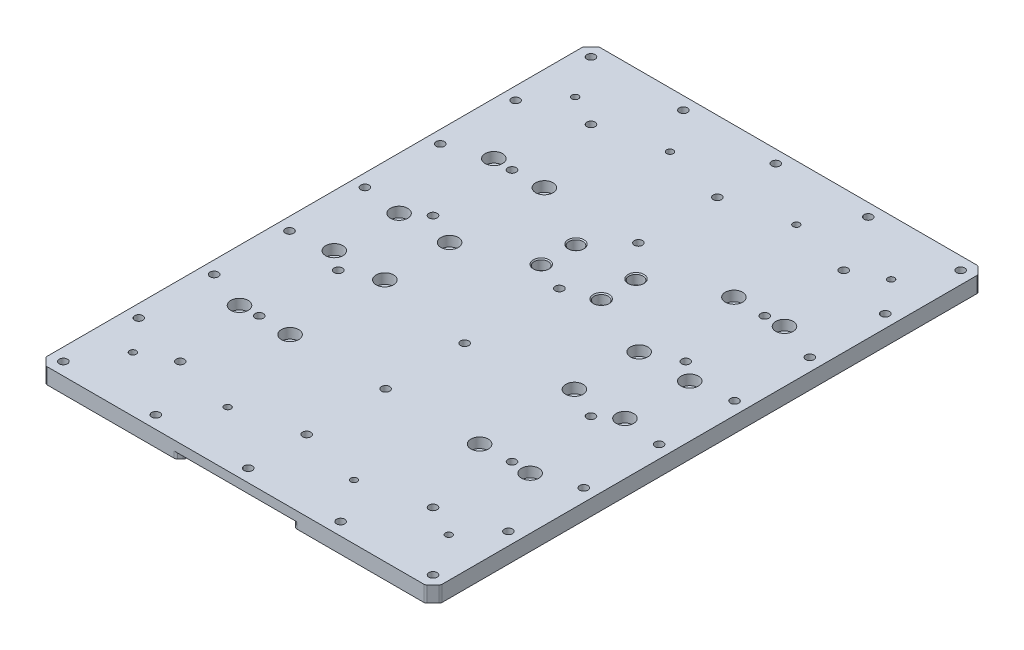
from build123d import *

# Parameters (mm, degrees)
SKETCH1_W                                           = 250
SKETCH1_H                                           = 350
BOSS_EXTRUDE1_DEPTH                                 = 10
CBORE_FOR_M5_HEX_SOCKET_HEAD_CAP_SCR_2_COUNT        = 2
CBORE_FOR_M5_HEX_SOCKET_HEAD_CAP_SCR_2_PITCH        = 22
CBORE_FOR_M5_HEX_SOCKET_HEAD_CAP_SCR_3_COUNT        = 2
CBORE_FOR_M5_HEX_SOCKET_HEAD_CAP_SCR_3_PITCH        = 43.9089968
CBORE_FOR_M5_HEX_SOCKET_HEAD_CAP_SCR_4_COUNT        = 2
CBORE_FOR_M5_HEX_SOCKET_HEAD_CAP_SCR_4_PITCH        = 38
CHAMFER1_SIZE                                       = 5
CUT_EXTRUDE1_REACH                                  = 12
SKETCH4_R                                           = 2.6
CBORE_FOR_M6_HEX_SOCKET_HEAD_CAP_SCREW1_D           = 6.2
CBORE_FOR_M6_HEX_SOCKET_HEAD_CAP_SCREW1_CBORE_D     = 11
CBORE_FOR_M6_HEX_SOCKET_HEAD_CAP_SCREW1_CBORE_DEPTH = 6.4
SKETCH7_W                                           = 70
SKETCH7_H                                           = 160
CUT_EXTRUDE2_DEPTH                                  = 4
CHAMFER2_SIZE                                       = 3
FILLET1_R                                           = 2
M5_TAPPED_HOLE1_D                                   = 4.2
M5_TAPPED_HOLE1_DEPTH                               = 14
M5_TAPPED_HOLE1_TIP                                 = 1.2618073
M6_TAPPED_HOLE1_D                                   = 5.2
M6_TAPPED_HOLE1_DEPTH                               = 17
M6_TAPPED_HOLE1_TIP                                 = 1.562237609


with BuildPart() as part:
    # Sketch1 → Boss-Extrude1 (new body)
    with BuildSketch(Plane(origin=(0, 0, 0), x_dir=(1, 0, 0), z_dir=(0, 1, 0))):
        with Locations((125, 175)):
            Rectangle(SKETCH1_W, SKETCH1_H)
    extrude(amount=BOSS_EXTRUDE1_DEPTH)

    # Sketch3 → CBORE for M5 Hex Socket Head Cap Screw1 (revolve, cut)
    with BuildSketch(Plane(origin=(106, 10, -234.5), x_dir=(0, 0, 1), z_dir=(1, 0, 0))):
        Polygon((0, 0), (0, 10), (2.75, 10), (2.75, 6.5), (4.4, 6.5), (4.4, 0.625), (5.025, 0), align=None)
    cbore_for_m5_hex_socket_head_cap_screw1 = revolve(axis=Axis((106, 16.35, -234.5), (0, -1, 0)), mode=Mode.SUBTRACT)

    # CBORE for M5 Hex Socket Head Cap Scr 2: CBORE for M5 Hex Socket Head Cap Screw1 ×2
    with Locations(*[(0, 0, i * CBORE_FOR_M5_HEX_SOCKET_HEAD_CAP_SCR_2_PITCH) for i in range(1, CBORE_FOR_M5_HEX_SOCKET_HEAD_CAP_SCR_2_COUNT)]):
        add(cbore_for_m5_hex_socket_head_cap_screw1, mode=Mode.SUBTRACT)

    # CBORE for M5 Hex Socket Head Cap Scr 3: CBORE for M5 Hex Socket Head Cap Screw1 ×2
    with Locations(*[Vector(0.865426285, 0, 0.501036271) * (i * CBORE_FOR_M5_HEX_SOCKET_HEAD_CAP_SCR_3_PITCH) for i in range(1, CBORE_FOR_M5_HEX_SOCKET_HEAD_CAP_SCR_3_COUNT)]):
        add(cbore_for_m5_hex_socket_head_cap_screw1, mode=Mode.SUBTRACT)

    # CBORE for M5 Hex Socket Head Cap Scr 4: CBORE for M5 Hex Socket Head Cap Screw1 ×2
    with Locations(*[(i * CBORE_FOR_M5_HEX_SOCKET_HEAD_CAP_SCR_4_PITCH, 0, 0) for i in range(1, CBORE_FOR_M5_HEX_SOCKET_HEAD_CAP_SCR_4_COUNT)]):
        add(cbore_for_m5_hex_socket_head_cap_screw1, mode=Mode.SUBTRACT)

    # Chamfer1
    chamfer1_edges = [part.edges().sort_by_distance(p)[0] for p in [
        (0, 5, 0),
        (0, 5, -350),
        (250, 5, -350),
        (250, 5, 0),
    ]]
    chamfer(chamfer1_edges, length=CHAMFER1_SIZE)

    # Sketch4 → Cut-Extrude1 (cut, up to next)
    with BuildSketch(Plane(origin=(0, 10, 0), x_dir=(1, 0, 0), z_dir=(0, 1, 0)), mode=Mode.PRIVATE) as cut_extrude1_sk1:
        with Locations((8, 342)):
            Circle(SKETCH4_R)
    cut_extrude1_tool1 = extrude(cut_extrude1_sk1.sketch, amount=-CUT_EXTRUDE1_REACH, mode=Mode.PRIVATE) & part.part
    add(cut_extrude1_tool1.solids().sort_by_distance((8, 10, -342))[0], mode=Mode.SUBTRACT)
    # Sketch4 → Cut-Extrude1 (cut, up to next)
    with BuildSketch(Plane(origin=(0, 10, 0), x_dir=(1, 0, 0), z_dir=(0, 1, 0)), mode=Mode.PRIVATE) as cut_extrude1_sk2:
        with Locations((66.5, 342)):
            Circle(SKETCH4_R)
    cut_extrude1_tool2 = extrude(cut_extrude1_sk2.sketch, amount=-CUT_EXTRUDE1_REACH, mode=Mode.PRIVATE) & part.part
    add(cut_extrude1_tool2.solids().sort_by_distance((66.5, 10, -342))[0], mode=Mode.SUBTRACT)
    # Sketch4 → Cut-Extrude1 (cut, up to next)
    with BuildSketch(Plane(origin=(0, 10, 0), x_dir=(1, 0, 0), z_dir=(0, 1, 0)), mode=Mode.PRIVATE) as cut_extrude1_sk3:
        with Locations((125, 342)):
            Circle(SKETCH4_R)
    cut_extrude1_tool3 = extrude(cut_extrude1_sk3.sketch, amount=-CUT_EXTRUDE1_REACH, mode=Mode.PRIVATE) & part.part
    add(cut_extrude1_tool3.solids().sort_by_distance((125, 10, -342))[0], mode=Mode.SUBTRACT)
    # Sketch4 → Cut-Extrude1 (cut, up to next)
    with BuildSketch(Plane(origin=(0, 10, 0), x_dir=(1, 0, 0), z_dir=(0, 1, 0)), mode=Mode.PRIVATE) as cut_extrude1_sk4:
        with Locations((8, 294.286)):
            Circle(SKETCH4_R)
    cut_extrude1_tool4 = extrude(cut_extrude1_sk4.sketch, amount=-CUT_EXTRUDE1_REACH, mode=Mode.PRIVATE) & part.part
    add(cut_extrude1_tool4.solids().sort_by_distance((8, 10, -294.286))[0], mode=Mode.SUBTRACT)
    # Sketch4 → Cut-Extrude1 (cut, up to next)
    with BuildSketch(Plane(origin=(0, 10, 0), x_dir=(1, 0, 0), z_dir=(0, 1, 0)), mode=Mode.PRIVATE) as cut_extrude1_sk5:
        with Locations((8, 246.572)):
            Circle(SKETCH4_R)
    cut_extrude1_tool5 = extrude(cut_extrude1_sk5.sketch, amount=-CUT_EXTRUDE1_REACH, mode=Mode.PRIVATE) & part.part
    add(cut_extrude1_tool5.solids().sort_by_distance((8, 10, -246.572))[0], mode=Mode.SUBTRACT)
    # Sketch4 → Cut-Extrude1 (cut, up to next)
    with BuildSketch(Plane(origin=(0, 10, 0), x_dir=(1, 0, 0), z_dir=(0, 1, 0)), mode=Mode.PRIVATE) as cut_extrude1_sk6:
        with Locations((8, 198.858)):
            Circle(SKETCH4_R)
    cut_extrude1_tool6 = extrude(cut_extrude1_sk6.sketch, amount=-CUT_EXTRUDE1_REACH, mode=Mode.PRIVATE) & part.part
    add(cut_extrude1_tool6.solids().sort_by_distance((8, 10, -198.858))[0], mode=Mode.SUBTRACT)
    # Sketch4 → Cut-Extrude1 (cut, up to next)
    with BuildSketch(Plane(origin=(0, 10, 0), x_dir=(1, 0, 0), z_dir=(0, 1, 0)), mode=Mode.PRIVATE) as cut_extrude1_sk7:
        with Locations((183.5, 342)):
            Circle(SKETCH4_R)
    cut_extrude1_tool7 = extrude(cut_extrude1_sk7.sketch, amount=-CUT_EXTRUDE1_REACH, mode=Mode.PRIVATE) & part.part
    add(cut_extrude1_tool7.solids().sort_by_distance((183.5, 10, -342))[0], mode=Mode.SUBTRACT)
    # Sketch4 → Cut-Extrude1 (cut, up to next)
    with BuildSketch(Plane(origin=(0, 10, 0), x_dir=(1, 0, 0), z_dir=(0, 1, 0)), mode=Mode.PRIVATE) as cut_extrude1_sk8:
        with Locations((242, 198.858)):
            Circle(SKETCH4_R)
    cut_extrude1_tool8 = extrude(cut_extrude1_sk8.sketch, amount=-CUT_EXTRUDE1_REACH, mode=Mode.PRIVATE) & part.part
    add(cut_extrude1_tool8.solids().sort_by_distance((242, 10, -198.858))[0], mode=Mode.SUBTRACT)
    # Sketch4 → Cut-Extrude1 (cut, up to next)
    with BuildSketch(Plane(origin=(0, 10, 0), x_dir=(1, 0, 0), z_dir=(0, 1, 0)), mode=Mode.PRIVATE) as cut_extrude1_sk9:
        with Locations((242, 246.572)):
            Circle(SKETCH4_R)
    cut_extrude1_tool9 = extrude(cut_extrude1_sk9.sketch, amount=-CUT_EXTRUDE1_REACH, mode=Mode.PRIVATE) & part.part
    add(cut_extrude1_tool9.solids().sort_by_distance((242, 10, -246.572))[0], mode=Mode.SUBTRACT)
    # Sketch4 → Cut-Extrude1 (cut, up to next)
    with BuildSketch(Plane(origin=(0, 10, 0), x_dir=(1, 0, 0), z_dir=(0, 1, 0)), mode=Mode.PRIVATE) as cut_extrude1_sk10:
        with Locations((242, 294.286)):
            Circle(SKETCH4_R)
    cut_extrude1_tool10 = extrude(cut_extrude1_sk10.sketch, amount=-CUT_EXTRUDE1_REACH, mode=Mode.PRIVATE) & part.part
    add(cut_extrude1_tool10.solids().sort_by_distance((242, 10, -294.286))[0], mode=Mode.SUBTRACT)
    # Sketch4 → Cut-Extrude1 (cut, up to next)
    with BuildSketch(Plane(origin=(0, 10, 0), x_dir=(1, 0, 0), z_dir=(0, 1, 0)), mode=Mode.PRIVATE) as cut_extrude1_sk11:
        with Locations((242, 342)):
            Circle(SKETCH4_R)
    cut_extrude1_tool11 = extrude(cut_extrude1_sk11.sketch, amount=-CUT_EXTRUDE1_REACH, mode=Mode.PRIVATE) & part.part
    add(cut_extrude1_tool11.solids().sort_by_distance((242, 10, -342))[0], mode=Mode.SUBTRACT)
    # Sketch4 → Cut-Extrude1 (cut, up to next)
    with BuildSketch(Plane(origin=(0, 10, 0), x_dir=(1, 0, 0), z_dir=(0, 1, 0)), mode=Mode.PRIVATE) as cut_extrude1_sk12:
        with Locations((242, 8)):
            Circle(SKETCH4_R)
    cut_extrude1_tool12 = extrude(cut_extrude1_sk12.sketch, amount=-CUT_EXTRUDE1_REACH, mode=Mode.PRIVATE) & part.part
    add(cut_extrude1_tool12.solids().sort_by_distance((242, 10, -8))[0], mode=Mode.SUBTRACT)
    # Sketch4 → Cut-Extrude1 (cut, up to next)
    with BuildSketch(Plane(origin=(0, 10, 0), x_dir=(1, 0, 0), z_dir=(0, 1, 0)), mode=Mode.PRIVATE) as cut_extrude1_sk13:
        with Locations((183.5, 8)):
            Circle(SKETCH4_R)
    cut_extrude1_tool13 = extrude(cut_extrude1_sk13.sketch, amount=-CUT_EXTRUDE1_REACH, mode=Mode.PRIVATE) & part.part
    add(cut_extrude1_tool13.solids().sort_by_distance((183.5, 10, -8))[0], mode=Mode.SUBTRACT)
    # Sketch4 → Cut-Extrude1 (cut, up to next)
    with BuildSketch(Plane(origin=(0, 10, 0), x_dir=(1, 0, 0), z_dir=(0, 1, 0)), mode=Mode.PRIVATE) as cut_extrude1_sk14:
        with Locations((125, 8)):
            Circle(SKETCH4_R)
    cut_extrude1_tool14 = extrude(cut_extrude1_sk14.sketch, amount=-CUT_EXTRUDE1_REACH, mode=Mode.PRIVATE) & part.part
    add(cut_extrude1_tool14.solids().sort_by_distance((125, 10, -8))[0], mode=Mode.SUBTRACT)
    # Sketch4 → Cut-Extrude1 (cut, up to next)
    with BuildSketch(Plane(origin=(0, 10, 0), x_dir=(1, 0, 0), z_dir=(0, 1, 0)), mode=Mode.PRIVATE) as cut_extrude1_sk15:
        with Locations((66.5, 8)):
            Circle(SKETCH4_R)
    cut_extrude1_tool15 = extrude(cut_extrude1_sk15.sketch, amount=-CUT_EXTRUDE1_REACH, mode=Mode.PRIVATE) & part.part
    add(cut_extrude1_tool15.solids().sort_by_distance((66.5, 10, -8))[0], mode=Mode.SUBTRACT)
    # Sketch4 → Cut-Extrude1 (cut, up to next)
    with BuildSketch(Plane(origin=(0, 10, 0), x_dir=(1, 0, 0), z_dir=(0, 1, 0)), mode=Mode.PRIVATE) as cut_extrude1_sk16:
        with Locations((8, 8)):
            Circle(SKETCH4_R)
    cut_extrude1_tool16 = extrude(cut_extrude1_sk16.sketch, amount=-CUT_EXTRUDE1_REACH, mode=Mode.PRIVATE) & part.part
    add(cut_extrude1_tool16.solids().sort_by_distance((8, 10, -8))[0], mode=Mode.SUBTRACT)
    # Sketch4 → Cut-Extrude1 (cut, up to next)
    with BuildSketch(Plane(origin=(0, 10, 0), x_dir=(1, 0, 0), z_dir=(0, 1, 0)), mode=Mode.PRIVATE) as cut_extrude1_sk17:
        with Locations((242, 55.714)):
            Circle(SKETCH4_R)
    cut_extrude1_tool17 = extrude(cut_extrude1_sk17.sketch, amount=-CUT_EXTRUDE1_REACH, mode=Mode.PRIVATE) & part.part
    add(cut_extrude1_tool17.solids().sort_by_distance((242, 10, -55.714))[0], mode=Mode.SUBTRACT)
    # Sketch4 → Cut-Extrude1 (cut, up to next)
    with BuildSketch(Plane(origin=(0, 10, 0), x_dir=(1, 0, 0), z_dir=(0, 1, 0)), mode=Mode.PRIVATE) as cut_extrude1_sk18:
        with Locations((242, 103.428)):
            Circle(SKETCH4_R)
    cut_extrude1_tool18 = extrude(cut_extrude1_sk18.sketch, amount=-CUT_EXTRUDE1_REACH, mode=Mode.PRIVATE) & part.part
    add(cut_extrude1_tool18.solids().sort_by_distance((242, 10, -103.428))[0], mode=Mode.SUBTRACT)
    # Sketch4 → Cut-Extrude1 (cut, up to next)
    with BuildSketch(Plane(origin=(0, 10, 0), x_dir=(1, 0, 0), z_dir=(0, 1, 0)), mode=Mode.PRIVATE) as cut_extrude1_sk19:
        with Locations((242, 151.142)):
            Circle(SKETCH4_R)
    cut_extrude1_tool19 = extrude(cut_extrude1_sk19.sketch, amount=-CUT_EXTRUDE1_REACH, mode=Mode.PRIVATE) & part.part
    add(cut_extrude1_tool19.solids().sort_by_distance((242, 10, -151.142))[0], mode=Mode.SUBTRACT)
    # Sketch4 → Cut-Extrude1 (cut, up to next)
    with BuildSketch(Plane(origin=(0, 10, 0), x_dir=(1, 0, 0), z_dir=(0, 1, 0)), mode=Mode.PRIVATE) as cut_extrude1_sk20:
        with Locations((8, 151.142)):
            Circle(SKETCH4_R)
    cut_extrude1_tool20 = extrude(cut_extrude1_sk20.sketch, amount=-CUT_EXTRUDE1_REACH, mode=Mode.PRIVATE) & part.part
    add(cut_extrude1_tool20.solids().sort_by_distance((8, 10, -151.142))[0], mode=Mode.SUBTRACT)
    # Sketch4 → Cut-Extrude1 (cut, up to next)
    with BuildSketch(Plane(origin=(0, 10, 0), x_dir=(1, 0, 0), z_dir=(0, 1, 0)), mode=Mode.PRIVATE) as cut_extrude1_sk21:
        with Locations((8, 103.428)):
            Circle(SKETCH4_R)
    cut_extrude1_tool21 = extrude(cut_extrude1_sk21.sketch, amount=-CUT_EXTRUDE1_REACH, mode=Mode.PRIVATE) & part.part
    add(cut_extrude1_tool21.solids().sort_by_distance((8, 10, -103.428))[0], mode=Mode.SUBTRACT)
    # Sketch4 → Cut-Extrude1 (cut, up to next)
    with BuildSketch(Plane(origin=(0, 10, 0), x_dir=(1, 0, 0), z_dir=(0, 1, 0)), mode=Mode.PRIVATE) as cut_extrude1_sk22:
        with Locations((8, 55.714)):
            Circle(SKETCH4_R)
    cut_extrude1_tool22 = extrude(cut_extrude1_sk22.sketch, amount=-CUT_EXTRUDE1_REACH, mode=Mode.PRIVATE) & part.part
    add(cut_extrude1_tool22.solids().sort_by_distance((8, 10, -55.714))[0], mode=Mode.SUBTRACT)

    # CBORE for M6 Hex Socket Head Cap Screw1 (through all)
    with Locations(Plane(origin=(33, 10, -255.5), x_dir=(0, 0, 1), z_dir=(0, 1, 0))):
        with Locations((0, 0), (0, 32), (0, 152), (60, 184), (60, 152), (101, 184), (101, 152), (161, 184), (161, 152), (161, 0), (161, 32), (101, 0), (101, 32), (60, 0), (60, 32), (0, 184)):
            CounterBoreHole(CBORE_FOR_M6_HEX_SOCKET_HEAD_CAP_SCREW1_D / 2, CBORE_FOR_M6_HEX_SOCKET_HEAD_CAP_SCREW1_CBORE_D / 2, CBORE_FOR_M6_HEX_SOCKET_HEAD_CAP_SCREW1_CBORE_DEPTH)

    # Sketch7 → Cut-Extrude2 (cut)
    with BuildSketch(Plane.XZ):
        with Locations((125, -80)):
            Rectangle(SKETCH7_W, SKETCH7_H)
    extrude(amount=-CUT_EXTRUDE2_DEPTH, mode=Mode.SUBTRACT)

    # Chamfer2
    chamfer2_edges = [part.edges().sort_by_distance(p)[0] for p in [
        (160, 2, 0),
        (90, 2, 0),
    ]]
    chamfer(chamfer2_edges, length=CHAMFER2_SIZE)

    # Fillet1
    fillet1_edges = [part.edges().sort_by_distance(p)[0] for p in [
        (87, 2, 0),
        (163, 2, 0),
        (160, 2, -3),
        (90, 2, -3),
        (0, 5, -5),
        (0, 5, -345),
        (245, 5, -350),
        (5, 5, -350),
        (245, 5, 0),
        (5, 5, 0),
        (250, 5, -5),
        (250, 5, -345),
    ]]
    fillet(fillet1_edges, radius=FILLET1_R)

    # M5 Tapped Hole1
    with Locations(Plane(origin=(25, 10, -35), x_dir=(0, 0, 1), z_dir=(0, 1, 0))):
        with Locations((0, 0), (0, 60), (0, 140), (0, 200), (-280, 0), (-280, 60), (-280, 140), (-280, 200)):
            Hole(M5_TAPPED_HOLE1_D / 2, depth=M5_TAPPED_HOLE1_DEPTH)
            with Locations((0, 0, -(M5_TAPPED_HOLE1_DEPTH + M5_TAPPED_HOLE1_TIP / 2))):  # 118° drill point
                Cone(0, M5_TAPPED_HOLE1_D / 2, M5_TAPPED_HOLE1_TIP, mode=Mode.SUBTRACT)

    # M6 Tapped Hole1
    with Locations(Plane(origin=(45, 10, -45), x_dir=(0, 0, 1), z_dir=(0, 1, 0))):
        with Locations((0, 0), (0, 160), (-50, 160), (-50, 0), (-100, 0), (-100, 160), (-160, 160), (-160, 0), (-210, 0), (-210, 160), (-260, 160), (-260, 0), (0, 80), (-50, 80), (-100, 80), (-160, 80), (-210, 80), (-260, 80)):
            Hole(M6_TAPPED_HOLE1_D / 2, depth=M6_TAPPED_HOLE1_DEPTH)
            with Locations((0, 0, -(M6_TAPPED_HOLE1_DEPTH + M6_TAPPED_HOLE1_TIP / 2))):  # 118° drill point
                Cone(0, M6_TAPPED_HOLE1_D / 2, M6_TAPPED_HOLE1_TIP, mode=Mode.SUBTRACT)


solid = part.part
